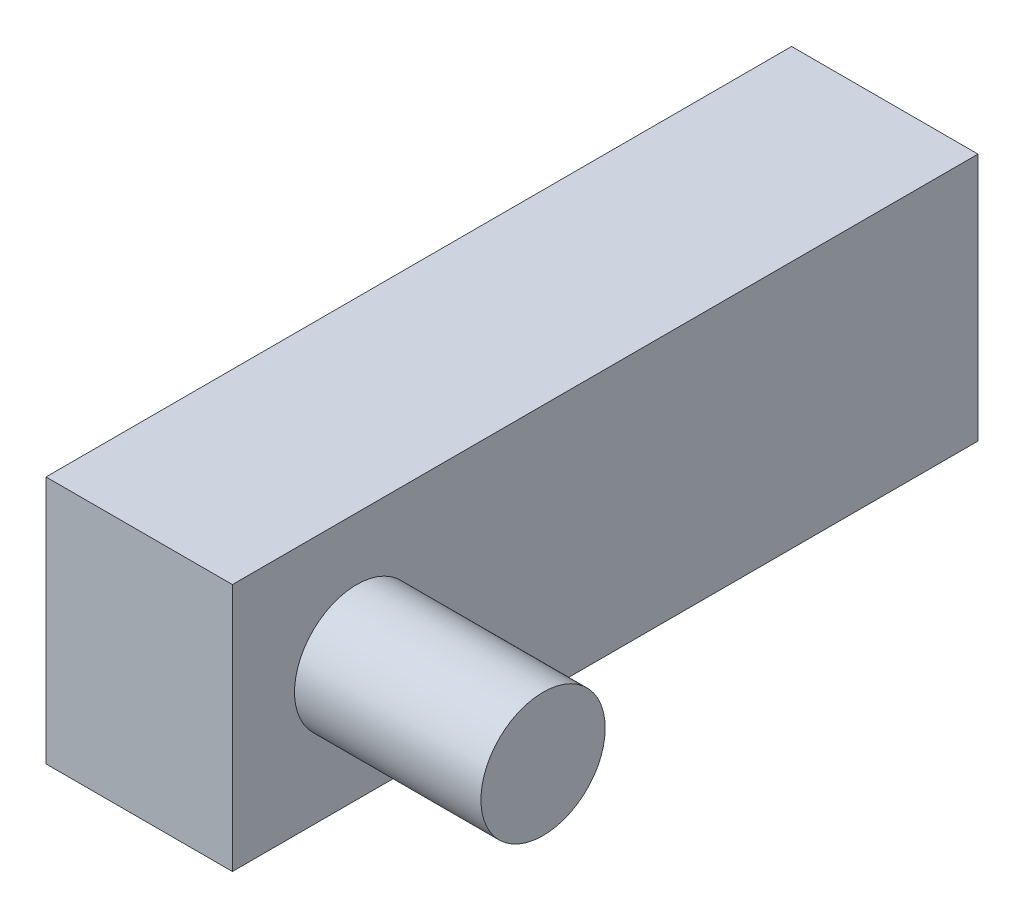
from build123d import *

# Parameters (mm, degrees)
SKETCH2_R                = 5
BOSS_EXTRUDE1_DEPTH      = 15
BOSS_EXTRUDE2_DEPTH      = 10
BOSS_EXTRUDE2_DEPTH_BACK = 50


with BuildPart() as part:
    # Sketch2 → Boss-Extrude1 (new body)
    with BuildSketch(Plane(origin=(0, 0, 0), x_dir=(0, 0, -1), z_dir=(1, 0, 0))):
        Circle(SKETCH2_R)
    extrude(amount=-BOSS_EXTRUDE1_DEPTH)

    # Sketch3 → Boss-Extrude2 (add, two sides)
    with BuildSketch(Plane.XY) as boss_extrude2_sk:
        Polygon((-15, 0), (-15, 10), (-30, 10), (-30, -10), (-15, -10), align=None)
    extrude(amount=BOSS_EXTRUDE2_DEPTH)
    extrude(boss_extrude2_sk.sketch, amount=-BOSS_EXTRUDE2_DEPTH_BACK)


solid = part.part
